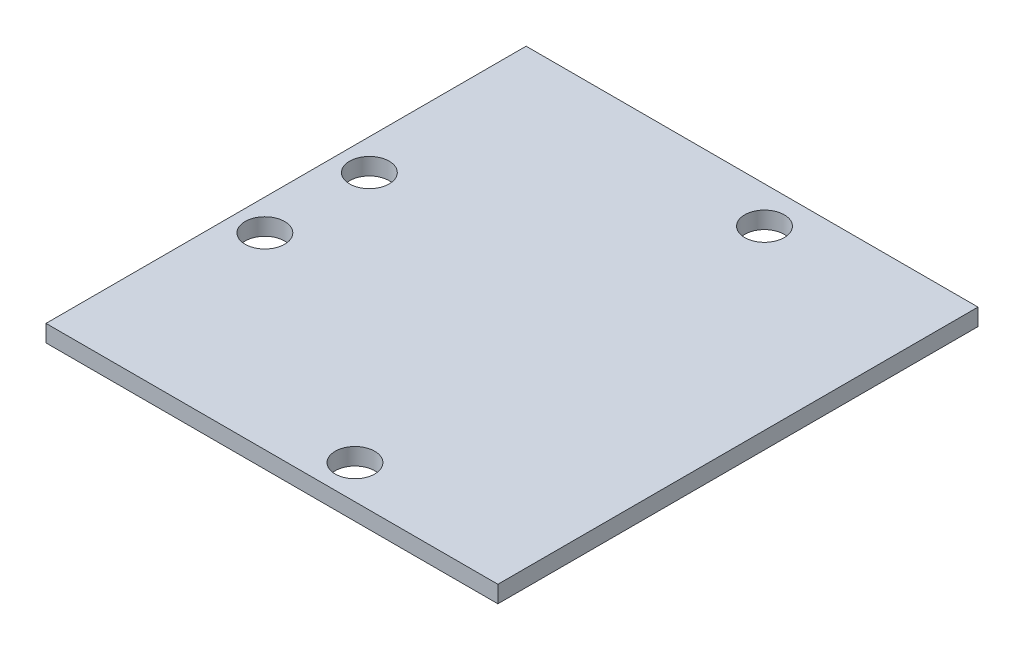
from build123d import *

# Parameters (mm, degrees)
SKETCH1_W           = 80
SKETCH1_H           = 85
BOSS_EXTRUDE1_DEPTH = 3
SKETCH2_R           = 3.5
CUT_EXTRUDE1_DEPTH  = 4


with BuildPart() as part:
    # Sketch1 → Boss-Extrude1 (new body)
    with BuildSketch(Plane(origin=(0, 0, 0), x_dir=(1, 0, 0), z_dir=(0, 1, 0))):
        with Locations((40, 42.5)):
            Rectangle(SKETCH1_W, SKETCH1_H)
    extrude(amount=BOSS_EXTRUDE1_DEPTH)

    # Sketch2 → Cut-Extrude1 (cut, through all)
    with BuildSketch(Plane(origin=(0, 3, 0), x_dir=(1, 0, 0), z_dir=(0, 1, 0))):
        with Locations((5.5, 33.25)):
            Circle(SKETCH2_R)
        with Locations((5.5, 51.75)):
            Circle(SKETCH2_R)
        with Locations((48.7, 78.5)):
            Circle(SKETCH2_R)
        with Locations((48.7, 6)):
            Circle(SKETCH2_R)
    extrude(amount=-CUT_EXTRUDE1_DEPTH, mode=Mode.SUBTRACT)


solid = part.part
